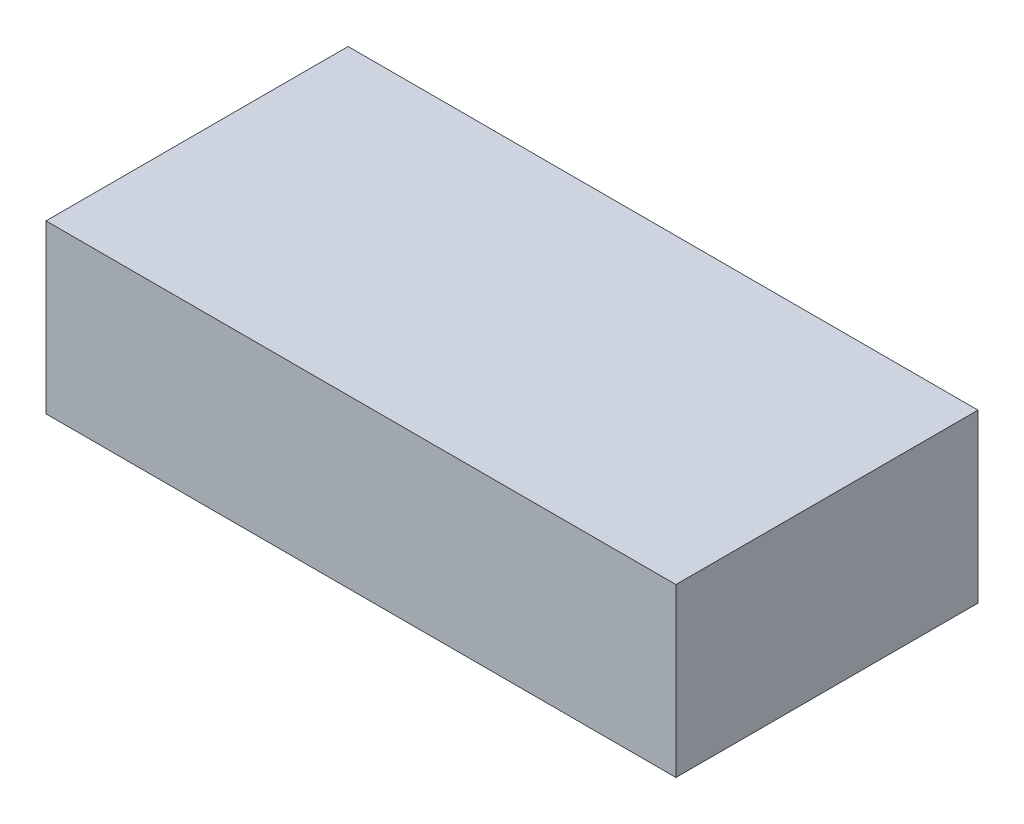
from build123d import *

# Parameters (mm, degrees)
SKETCH1_W           = 49
SKETCH1_H           = 23.5
BOSS_EXTRUDE1_DEPTH = 13


with BuildPart() as part:
    # Sketch1 → Boss-Extrude1 (new body)
    with BuildSketch(Plane(origin=(0, 0, 0), x_dir=(1, 0, 0), z_dir=(0, 1, 0))):
        Rectangle(SKETCH1_W, SKETCH1_H)
    extrude(amount=BOSS_EXTRUDE1_DEPTH)


solid = part.part
